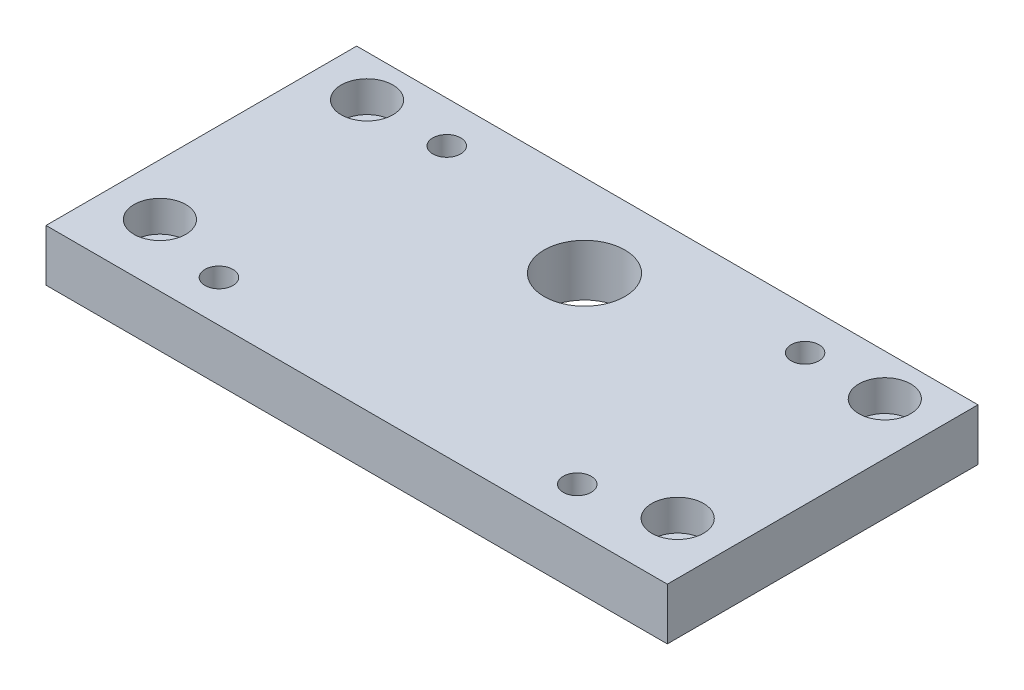
from build123d import *

# Parameters (mm, degrees)
SKETCH1_W           = 60
SKETCH1_H           = 30
BOSS_EXTRUDE1_DEPTH = 5
SKETCH3_R           = 3.9
SKETCH3_R_2         = 1.35
CUT_EXTRUDE1_DEPTH  = 5
SKETCH4_R           = 1.25
CUT_EXTRUDE2_DEPTH  = 5
SKETCH5_R           = 2.5
CUT_EXTRUDE3_DEPTH  = 3


with BuildPart() as part:
    # Sketch1 → Boss-Extrude1 (new body)
    with BuildSketch(Plane(origin=(0, 0, 0), x_dir=(1, 0, 0), z_dir=(0, 1, 0))):
        with Locations((30, 15)):
            Rectangle(SKETCH1_W, SKETCH1_H)
    extrude(amount=BOSS_EXTRUDE1_DEPTH)

    # Sketch3 → Cut-Extrude1 (cut)
    with BuildSketch(Plane(origin=(0, 5, 0), x_dir=(1, 0, 0), z_dir=(0, 1, 0))):
        with Locations((30, 22)):
            Circle(SKETCH3_R)
        with Locations((47.3, 4)):
            Circle(SKETCH3_R_2)
        with Locations((47.3, 26)):
            Circle(SKETCH3_R_2)
    cut_extrude1 = extrude(amount=-CUT_EXTRUDE1_DEPTH, mode=Mode.SUBTRACT)

    # Mirror1: Cut-Extrude1 across plane
    add(cut_extrude1.mirror(Plane.ZY.offset(-30)), mode=Mode.SUBTRACT)

    # Sketch4 → Cut-Extrude2 (cut)
    with BuildSketch(Plane(origin=(0, 5, 0), x_dir=(1, 0, 0), z_dir=(0, 1, 0))):
        with Locations((55, 26)):
            Circle(SKETCH4_R)
        with Locations((55, 6)):
            Circle(SKETCH4_R)
    cut_extrude2 = extrude(amount=-CUT_EXTRUDE2_DEPTH, mode=Mode.SUBTRACT)

    # Mirror2: Cut-Extrude2 across plane
    add(cut_extrude2.mirror(Plane.ZY.offset(-30)), mode=Mode.SUBTRACT)

    # Sketch5 → Cut-Extrude3 (cut)
    with BuildSketch(Plane(origin=(0, 5, 0), x_dir=(1, 0, 0), z_dir=(0, 1, 0))):
        with Locations((55, 26)):
            Circle(SKETCH5_R)
        with Locations((55, 6)):
            Circle(SKETCH5_R)
    cut_extrude3 = extrude(amount=-CUT_EXTRUDE3_DEPTH, mode=Mode.SUBTRACT)

    # Mirror3: Cut-Extrude3 across plane
    add(cut_extrude3.mirror(Plane.ZY.offset(-30)), mode=Mode.SUBTRACT)


solid = part.part
